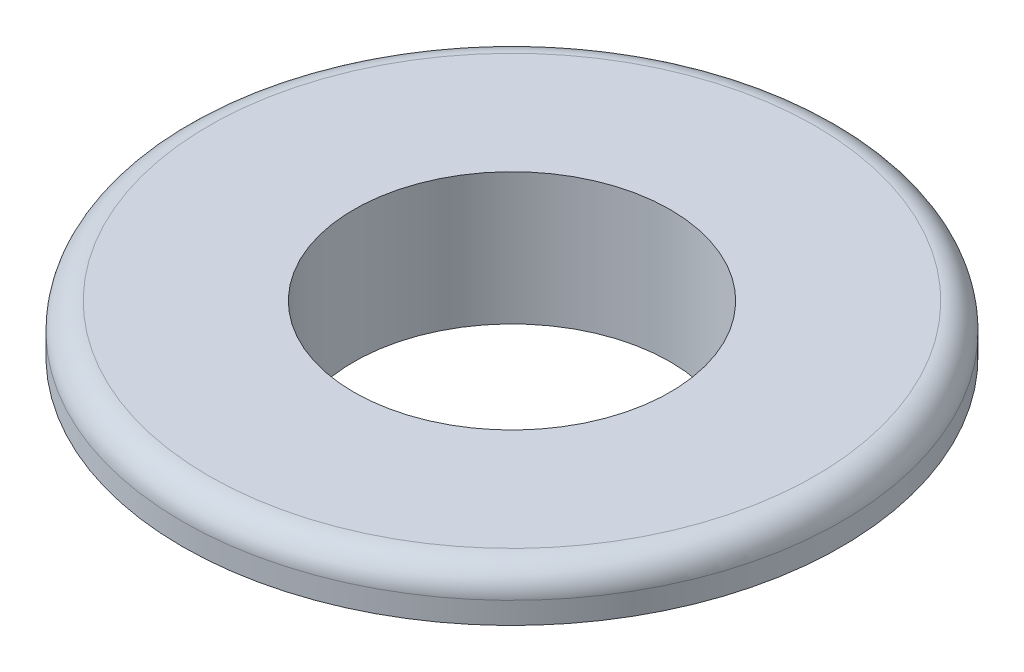
from build123d import *

# Parameters (mm, degrees)
SKETCH1_R           = 7
SKETCH1_R_2         = 6
BOSS_EXTRUDE1_DEPTH = 3.175
SKETCH2_R           = 12.5
SKETCH2_R_2         = 6
BOSS_EXTRUDE2_DEPTH = 1.825
FILLET1_R           = 1


with BuildPart() as part:
    # Sketch1 → Boss-Extrude1 (new body)
    with BuildSketch(Plane(origin=(0, 0, 0), x_dir=(1, 0, 0), z_dir=(0, 1, 0))):
        Circle(SKETCH1_R)
        Circle(SKETCH1_R_2, mode=Mode.SUBTRACT)
    extrude(amount=BOSS_EXTRUDE1_DEPTH)

    # Sketch2 → Boss-Extrude2 (add)
    with BuildSketch(Plane(origin=(0, 3.175, 0), x_dir=(1, 0, 0), z_dir=(0, 1, 0))):
        Circle(SKETCH2_R)
        Circle(SKETCH2_R_2, mode=Mode.SUBTRACT)
    extrude(amount=BOSS_EXTRUDE2_DEPTH)

    # Fillet1
    fillet1_edges = [part.edges().sort_by_distance(p)[0] for p in [
        (-12.5, 5, 0),
    ]]
    fillet(fillet1_edges, radius=FILLET1_R)


solid = part.part
